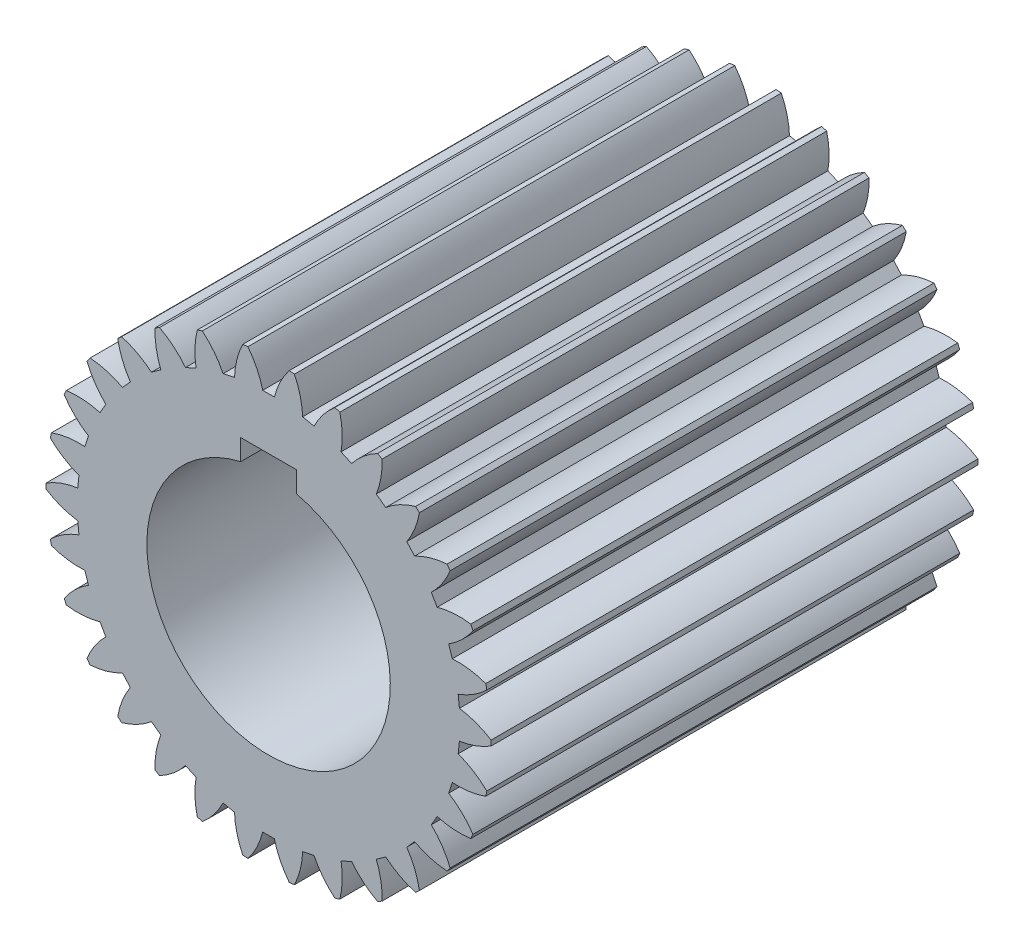
from build123d import *

# Parameters (mm, degrees)
SKETCH1_R           = 32
BOSS_EXTRUDE1_DEPTH = 70
CUT_EXTRUDE1_DEPTH  = 70
CIRPATTERN1_COUNT   = 30
CUT_EXTRUDE2_DEPTH  = 70


with BuildPart() as part:
    # Sketch1 → Boss-Extrude1 (new body)
    with BuildSketch(Plane.XY):
        Circle(SKETCH1_R)
    extrude(amount=BOSS_EXTRUDE1_DEPTH)

    # Sketch3 → Cut-Extrude1 (cut)
    with BuildSketch(Plane.XY.offset(70)):
        with BuildLine():
            Line((3.082235405, 32), (-3.082235405, 32))
            ThreePointArc((-3.082235405, 32), (-1.716298742, 29.871791027), (-0.838993939, 27.5))
            Line((-0.838993939, 27.5), (0.838993939, 27.5))
            ThreePointArc((0.838993939, 27.5), (1.716298742, 29.871791027), (3.082235405, 32))
        make_face()
    cut_extrude1 = extrude(amount=-CUT_EXTRUDE1_DEPTH, mode=Mode.SUBTRACT)

    # CirPattern1: Cut-Extrude1 ×30 about axis
    cirpattern1_axis = Axis((0, 0, 0), (0, 0, 1))
    for i in range(1, CIRPATTERN1_COUNT):
        add(cut_extrude1.rotate(cirpattern1_axis, i * 360 / CIRPATTERN1_COUNT), mode=Mode.SUBTRACT)

    # Sketch4 → Cut-Extrude2 (cut)
    with BuildSketch(Plane.XY.offset(70)):
        with BuildLine():
            Line((-4, 17.036725037), (-4, 20.036725037))
            Line((-4, 20.036725037), (4, 20.036725037))
            Line((4, 20.036725037), (4, 17.036725037))
            ThreePointArc((4, 17.036725037), (0, -17.5), (-4, 17.036725037))
        make_face()
    extrude(amount=-CUT_EXTRUDE2_DEPTH, mode=Mode.SUBTRACT)


solid = part.part
